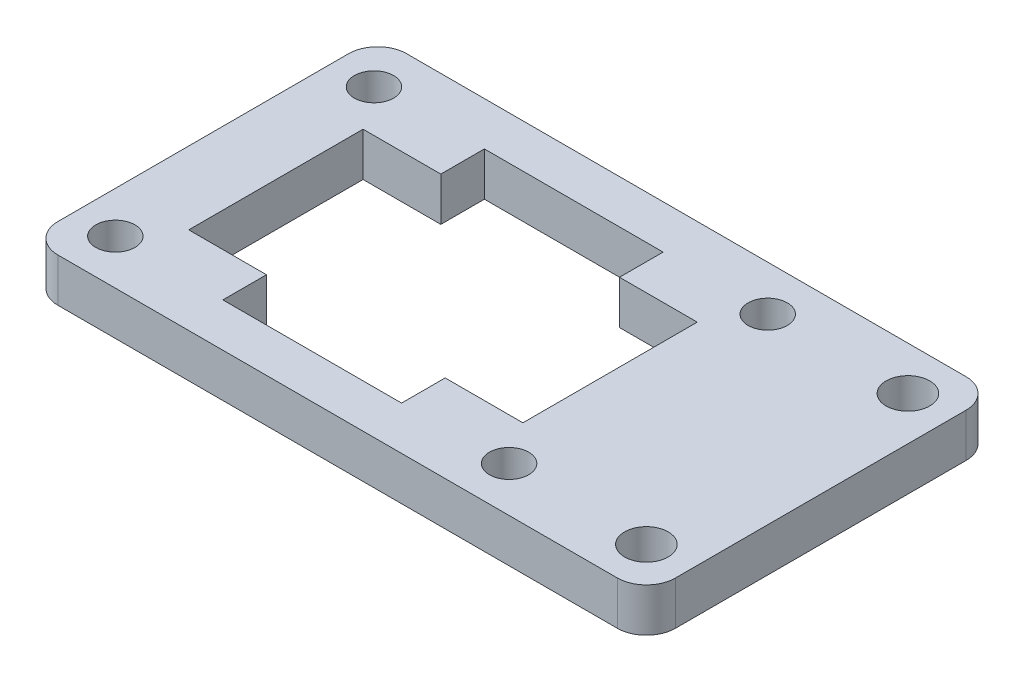
from build123d import *

# Parameters (mm, degrees)
SKETCH1_W           = 42.5
SKETCH1_H           = 24
SKETCH1_R           = 1.35
SKETCH1_R_2         = 1.5
BOSS_EXTRUDE1_DEPTH = 3
SKETCH2_W           = 0.15
SKETCH2_H           = 3
CUT_EXTRUDE1_DEPTH  = 4
FILLET1_R           = 2


with BuildPart() as part:
    # Sketch1 → Boss-Extrude1 (new body)
    with BuildSketch(Plane(origin=(0, 0, 0), x_dir=(1, 0, 0), z_dir=(0, 1, 0))):
        with Locations((21.25, 12)):
            Rectangle(SKETCH1_W, SKETCH1_H)
        with Locations((2.85, 3.1)):
            Circle(SKETCH1_R, mode=Mode.SUBTRACT)
        with Locations((29.95, 3.1)):
            Circle(SKETCH1_R, mode=Mode.SUBTRACT)
        with Locations((39.5, 3)):
            Circle(SKETCH1_R_2, mode=Mode.SUBTRACT)
        Polygon((5, 6), (5, 18), (10.5, 18), (10.5, 21), (22.5, 21), (22.5, 18), (28, 18), (28, 6), (22.5, 6), (22.5, 3), (10.5, 3), (10.5, 6), align=None, mode=Mode.SUBTRACT)
        with Locations((2.85, 20.9)):
            Circle(SKETCH1_R, mode=Mode.SUBTRACT)
        with Locations((29.95, 20.9)):
            Circle(SKETCH1_R, mode=Mode.SUBTRACT)
        with Locations((39.5, 21)):
            Circle(SKETCH1_R_2, mode=Mode.SUBTRACT)
    extrude(amount=BOSS_EXTRUDE1_DEPTH)

    # Sketch2 → Cut-Extrude1 (cut, through all)
    with BuildSketch(Plane(origin=(0, 3, 0), x_dir=(1, 0, 0), z_dir=(0, 1, 0))):
        with Locations((22.575, 4.5)):
            Rectangle(SKETCH2_W, SKETCH2_H)
        with Locations((10.425, 4.5)):
            Rectangle(SKETCH2_W, SKETCH2_H)
        with Locations((22.575, 19.5)):
            Rectangle(SKETCH2_W, SKETCH2_H)
        with Locations((10.425, 19.5)):
            Rectangle(SKETCH2_W, SKETCH2_H)
    extrude(amount=-CUT_EXTRUDE1_DEPTH, mode=Mode.SUBTRACT)

    # Fillet1
    fillet1_edges = [part.edges().sort_by_distance(p)[0] for p in [
        (0, 1.5, 0),
        (0, 1.5, -24),
        (42.5, 1.5, -24),
        (42.5, 1.5, 0),
    ]]
    fillet(fillet1_edges, radius=FILLET1_R)


solid = part.part
